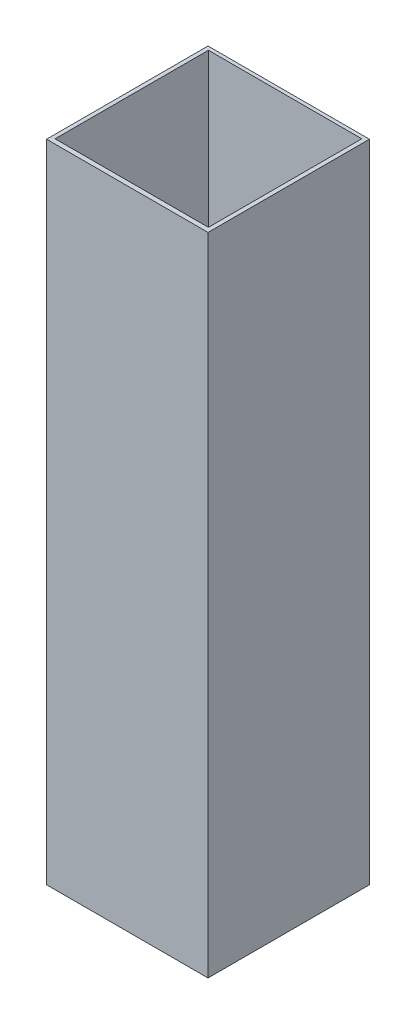
from build123d import *

# Parameters (mm, degrees)
SKETCH1_W           = 63.5
SKETCH1_H           = 63.5
SKETCH1_W_2         = 60.325
SKETCH1_H_2         = 60.325
BOSS_EXTRUDE1_DEPTH = 254
SKETCH3_W           = 60.325
SKETCH3_H           = 60.325
BOSS_EXTRUDE3_DEPTH = 2.54


with BuildPart() as part:
    # Sketch1 → Boss-Extrude1 (new body)
    with BuildSketch(Plane(origin=(0, 0, 0), x_dir=(1, 0, 0), z_dir=(0, 1, 0))):
        with Locations((-4.163673182, -5.031735612)):
            Rectangle(SKETCH1_W, SKETCH1_H)
        with Locations((-4.220828178, -4.80555794)):
            Rectangle(SKETCH1_W_2, SKETCH1_H_2, mode=Mode.SUBTRACT)
    extrude(amount=BOSS_EXTRUDE1_DEPTH)

    # Sketch3 → Boss-Extrude3 (add)
    with BuildSketch(Plane(origin=(0, 152.4, 0), x_dir=(1, 0, 0), z_dir=(0, 1, 0))):
        with Locations((-4.220828178, -4.80555794)):
            Rectangle(SKETCH3_W, SKETCH3_H)
    extrude(amount=-BOSS_EXTRUDE3_DEPTH)


solid = part.part
